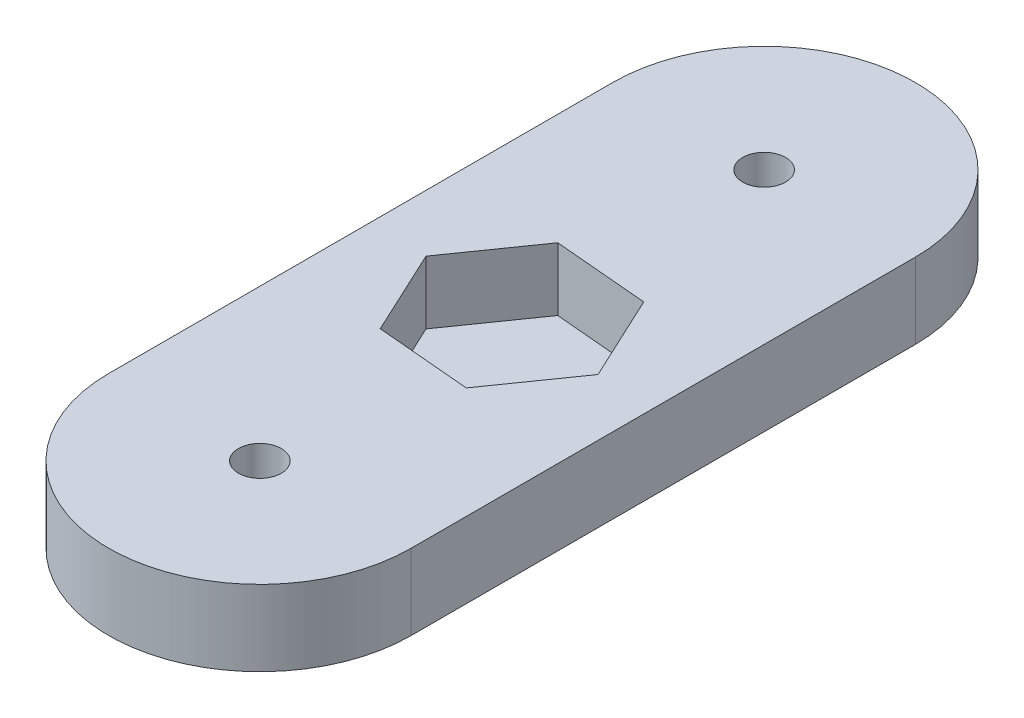
from build123d import *

# Parameters (mm, degrees)
SKETCH1_R           = 1.7
BOSS_EXTRUDE1_DEPTH = 6
CUT_EXTRUDE1_DEPTH  = 5


with BuildPart() as part:
    # Sketch1 → Boss-Extrude1 (new body)
    with BuildSketch(Plane(origin=(0, 0, 0), x_dir=(1, 0, 0), z_dir=(0, 1, 0))):
        with BuildLine():
            Line((-12, 0), (-12, 40))
            ThreePointArc((-12, 40), (0, 52), (12, 40))
            Line((12, 40), (12, 0))
            ThreePointArc((12, 0), (0, -12), (-12, 0))
        make_face()
        with Locations((0, 40)):
            Circle(SKETCH1_R, mode=Mode.SUBTRACT)
        Circle(SKETCH1_R, mode=Mode.SUBTRACT)
    extrude(amount=BOSS_EXTRUDE1_DEPTH)

    # Sketch2 → Cut-Extrude1 (cut)
    with BuildSketch(Plane(origin=(0, 6, 0), x_dir=(1, 0, 0), z_dir=(0, 1, 0))):
        Polygon((3.171983973, 13.197658417), (7.476992602, 19.34584791), (4.305008629, 26.148189493), (-3.171983973, 26.802341583), (-7.476992602, 20.65415209), (-4.305008629, 13.851810507), align=None)
    extrude(amount=-CUT_EXTRUDE1_DEPTH, mode=Mode.SUBTRACT)


solid = part.part
